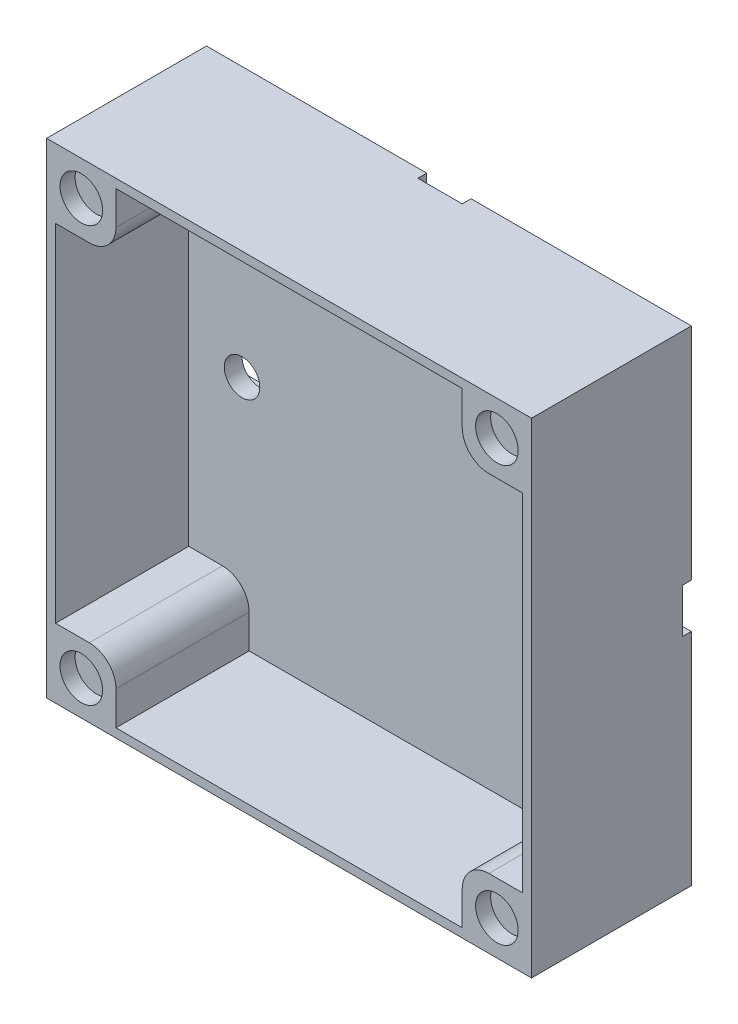
from build123d import *

# Parameters (mm, degrees)
SKICA1_W                 = 54.6
SKICA1_H                 = 54.6
P_IDAT_VYSUNUT_M2_DEPTH  = 3
SKICA5_W                 = 5
SKICA5_H                 = 24.8
SKICA5_W_2               = 54.6
SKICA5_H_2               = 5
ODEBRAT_VYSUNUT_M3_DEPTH = 1
SKICA14_W                = 52.6
SKICA14_H                = 1
P_IDAT_VYSUNUT_M9_DEPTH  = 15
SKICA17_R                = 2
ODEBRAT_VYSUNUT_M8_DEPTH = 7
SKICA19_W                = 7.8
SKICA19_H                = 7.8
P_IDAT_VYSUNUT_M10_DEPTH = 18
SKICA20_R                = 2.4
ODEBRAT_VYSUNUT_M9_DEPTH = 1.7
ZAOBLIT1_R               = 3


with BuildPart() as part:
    # Skica1 → Přidat vysunutím2 (new body)
    with BuildSketch(Plane.XY):
        Rectangle(SKICA1_W, SKICA1_H)
    extrude(amount=P_IDAT_VYSUNUT_M2_DEPTH)

    # Skica5 → Odebrat vysunutím3 (cut)
    with BuildSketch(Plane(origin=(0, 0, 0), x_dir=(-1, 0, 0), z_dir=(0, 0, -1))):
        with Locations((0, 14.9)):
            Rectangle(SKICA5_W, SKICA5_H)
        Rectangle(SKICA5_W_2, SKICA5_H_2)
    extrude(amount=-ODEBRAT_VYSUNUT_M3_DEPTH, mode=Mode.SUBTRACT)

    # Skica14 → Přidat vysunutím9 (add)
    with BuildSketch(Plane.XY.offset(3)):
        Polygon((27.3, 27.3), (-27.3, 27.3), (-27.3, -27.3), (-26.3, -27.3), (-26.3, -26.3), (-26.3, 26.3), (26.3, 26.3), (26.3, -26.3), (26.3, -27.3), (27.3, -27.3), align=None)
        with Locations((0, -26.8)):
            Rectangle(SKICA14_W, SKICA14_H)
    extrude(amount=P_IDAT_VYSUNUT_M9_DEPTH)

    # Skica17 → Odebrat vysunutím8 (cut)
    with BuildSketch(Plane(origin=(0, 0, 1), x_dir=(-1, 0, 0), z_dir=(0, 0, -1))):
        with Locations((-20.3, 0)):
            Circle(SKICA17_R)
        with Locations((20.3, 0)):
            Circle(SKICA17_R)
        with Locations((0, 20.3)):
            Circle(SKICA17_R)
    extrude(amount=-ODEBRAT_VYSUNUT_M8_DEPTH, mode=Mode.SUBTRACT)

    # Skica19 → Přidat vysunutím10 (add)
    with BuildSketch(Plane(origin=(0, 0, 0), x_dir=(-1, 0, 0), z_dir=(0, 0, -1))):
        with Locations((-23.4, 23.4)):
            Rectangle(SKICA19_W, SKICA19_H)
        with Locations((23.4, 23.4)):
            Rectangle(SKICA19_W, SKICA19_H)
        with Locations((-23.4, -23.4)):
            Rectangle(SKICA19_W, SKICA19_H)
        with Locations((23.4, -23.4)):
            Rectangle(SKICA19_W, SKICA19_H)
    extrude(amount=-P_IDAT_VYSUNUT_M10_DEPTH)

    # Skica20 → Odebrat vysunutím9 (cut)
    with BuildSketch(Plane.XY.offset(18)):
        with Locations((-23.4, -23.4)):
            Circle(SKICA20_R)
        with Locations((-23.4, 23.4)):
            Circle(SKICA20_R)
        with Locations((23.400280565, 23.4)):
            Circle(SKICA20_R)
        with Locations((23.400280565, -23.4)):
            Circle(SKICA20_R)
    extrude(amount=-ODEBRAT_VYSUNUT_M9_DEPTH, mode=Mode.SUBTRACT)

    # Zaoblit1
    zaoblit1_edges = [part.edges().sort_by_distance(p)[0] for p in [
        (-19.5, 19.5, 10.5),
        (19.5, -19.5, 10.5),
        (-19.5, -19.5, 10.5),
        (19.5, 19.5, 10.5),
    ]]
    fillet(zaoblit1_edges, radius=ZAOBLIT1_R)


solid = part.part
